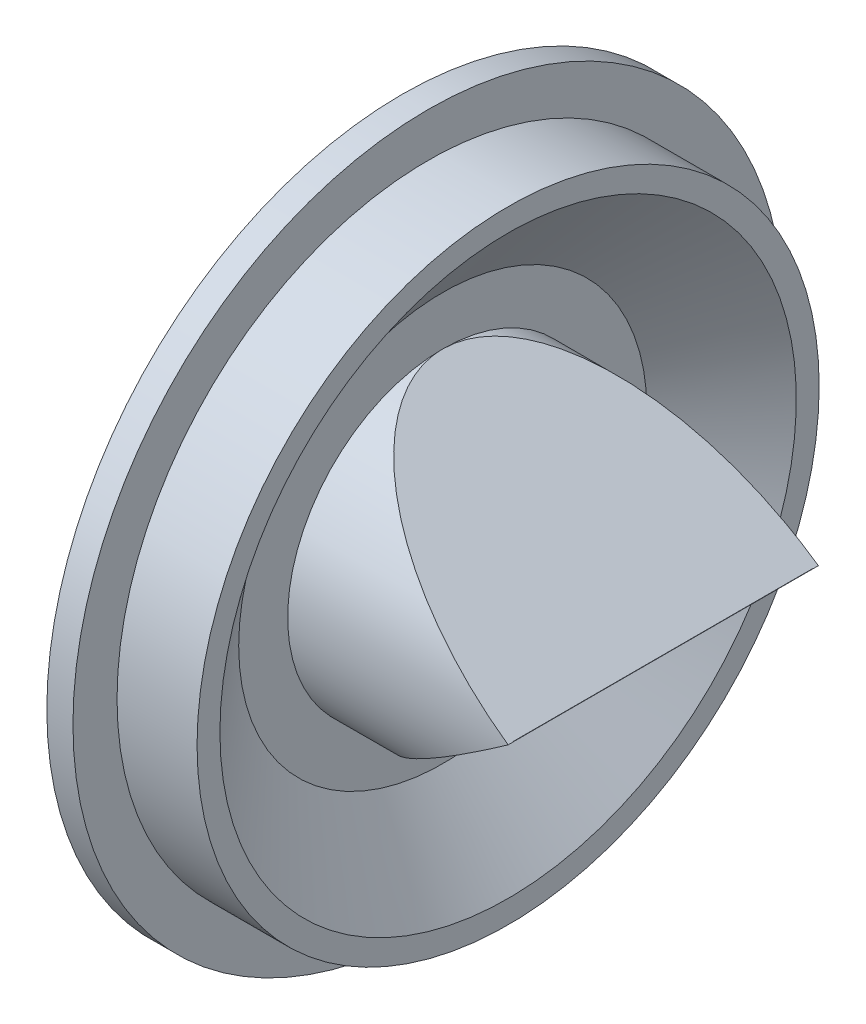
from build123d import *
from build123d.topology import SkipClean

# Parameters (mm, degrees)
SKETCH3_R               = 9.5
BOSS_EXTRUDE1_DEPTH     = 16
CUT_EXTRUDE1_DEPTH      = 21.892582416
CUT_EXTRUDE1_DEPTH_BACK = 21.892582416
SHELL7_T                = -0.3
SKETCH8_R               = 10.705762979
CUT_EXTRUDE5_DEPTH      = 10
CUT_EXTRUDE6_DEPTH      = 30


with BuildPart() as part:
    # Sketch3 → Boss-Extrude1 (new body)
    with BuildSketch(Plane.ZY):
        Circle(SKETCH3_R)
    extrude(amount=-BOSS_EXTRUDE1_DEPTH)

    # Sketch4 → Cut-Extrude1 (cut, two sides: drawn at the far end of the back side and taken through both)
    with BuildSketch(Plane.XY.offset(-CUT_EXTRUDE1_DEPTH_BACK)):
        Polygon((2.5, 9.5), (18.05891099, 17.267926144), (18.05891099, -17.267926144), (2.5, -9.5), (16, 0), align=None)
    extrude(amount=CUT_EXTRUDE1_DEPTH + CUT_EXTRUDE1_DEPTH_BACK, mode=Mode.SUBTRACT)

    # Shell7
    shell7_openings = [part.faces().sort_by_distance(p)[0] for p in [
        (0, 0, 0),
    ]]
    offset(amount=SHELL7_T, openings=shell7_openings, kind=Kind.INTERSECTION)

    # Sketch1 → Revolve1 (revolve)
    with SkipClean():  # the faces are left unmerged after this step: merging them gives an invalid solid
        with BuildSketch(Plane.XY, mode=Mode.PRIVATE) as revolve1_sk:
            Polygon((0, 18.75), (0, 21.75), (1.6, 21.75), (1.6, 19.05), (6.5, 19.05), (6.5, 17.65), (2.5, 12.5), (2.5, 9.5), (2.2, 9.5), (2.2, 12.602819589), (6.2, 17.752819589), (6.2, 18.75), align=None)
        revolve(revolve1_sk.sketch.rotate(Axis((0, 0, 0), (1, 0, 0)), 90), axis=Axis((0, 0, 0), (1, 0, 0)))

    # Sketch8 → Cut-Extrude5 (cut)
    with SkipClean():  # the faces are left unmerged after this step: merging them gives an invalid solid
        with BuildSketch(Plane.ZY.offset(-2.2)):
            Circle(SKETCH8_R)
        extrude(amount=CUT_EXTRUDE5_DEPTH, mode=Mode.SUBTRACT)

    # Sketch9 → Cut-Extrude6 (cut)
    with SkipClean():  # the faces are left unmerged after this step: merging them gives an invalid solid
        with BuildSketch(Plane.ZY.offset(-2.2)):
            with BuildLine():
                Line((-9.2, -0.01), (9.2, -0.01))
                ThreePointArc((9.2, -0.01), (9.200005435, 0), (9.2, 0.01))
                Line((9.2, 0.01), (-9.2, 0.01))
                ThreePointArc((-9.2, 0.01), (-9.200005435, 0), (-9.2, -0.01))
            make_face()
        extrude(amount=-CUT_EXTRUDE6_DEPTH, mode=Mode.SUBTRACT)


solid = part.part
